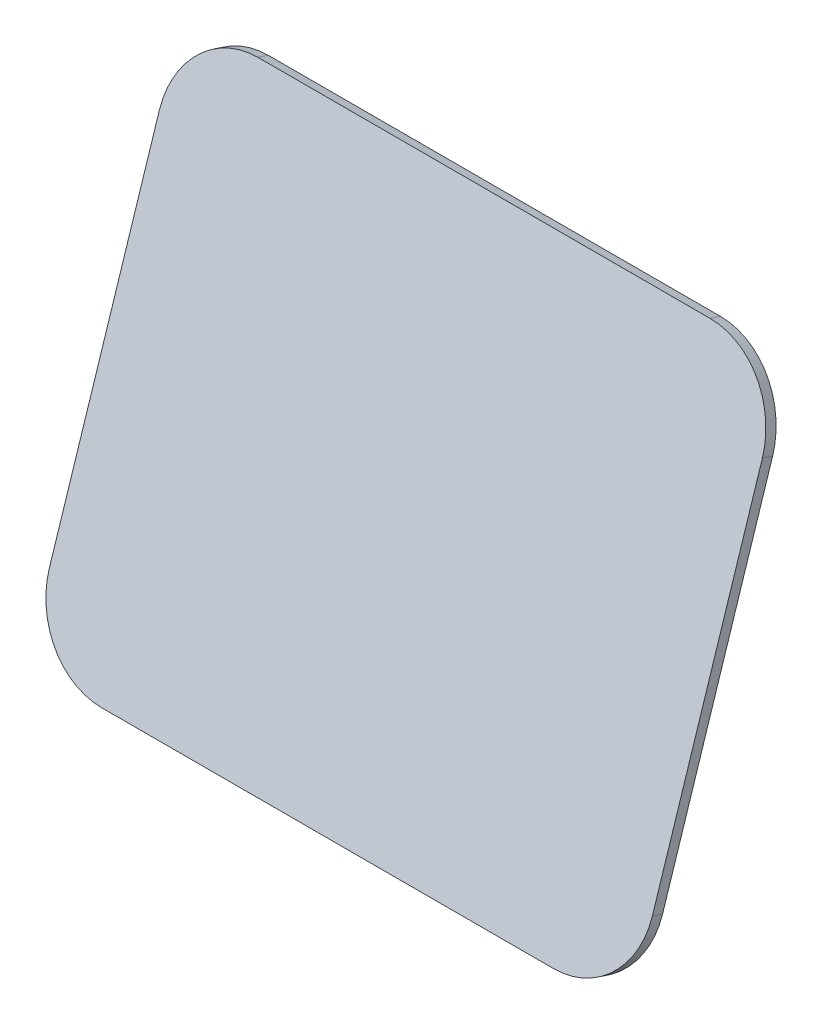
from build123d import *

# Parameters (mm, degrees)
BOSS_EXTRUDE1_DEPTH = 3


with BuildPart() as part:
    # Sketch1 → Boss-Extrude1 (new body)
    with BuildSketch(Plane(origin=(0, 68.253852605, 211.886836303), x_dir=(1, 0, 0), z_dir=(0, 0.306609139, 0.951835509))):
        with BuildLine():
            Line((84, 109.872559187), (84, 9.872559187))
            ThreePointArc((84, 9.872559187), (77.849242405, -4.976683218), (63, -11.127440813))
            Line((63, -11.127440813), (-63, -11.127440813))
            ThreePointArc((-63, -11.127440813), (-77.849242405, -4.976683218), (-84, 9.872559187))
            Line((-84, 9.872559187), (-84, 109.872559187))
            ThreePointArc((-84, 109.872559187), (-77.849242405, 124.721801592), (-63, 130.872559187))
            Line((-63, 130.872559187), (63, 130.872559187))
            ThreePointArc((63, 130.872559187), (77.849242405, 124.721801592), (84, 109.872559187))
        make_face()
    extrude(amount=BOSS_EXTRUDE1_DEPTH)


solid = part.part
